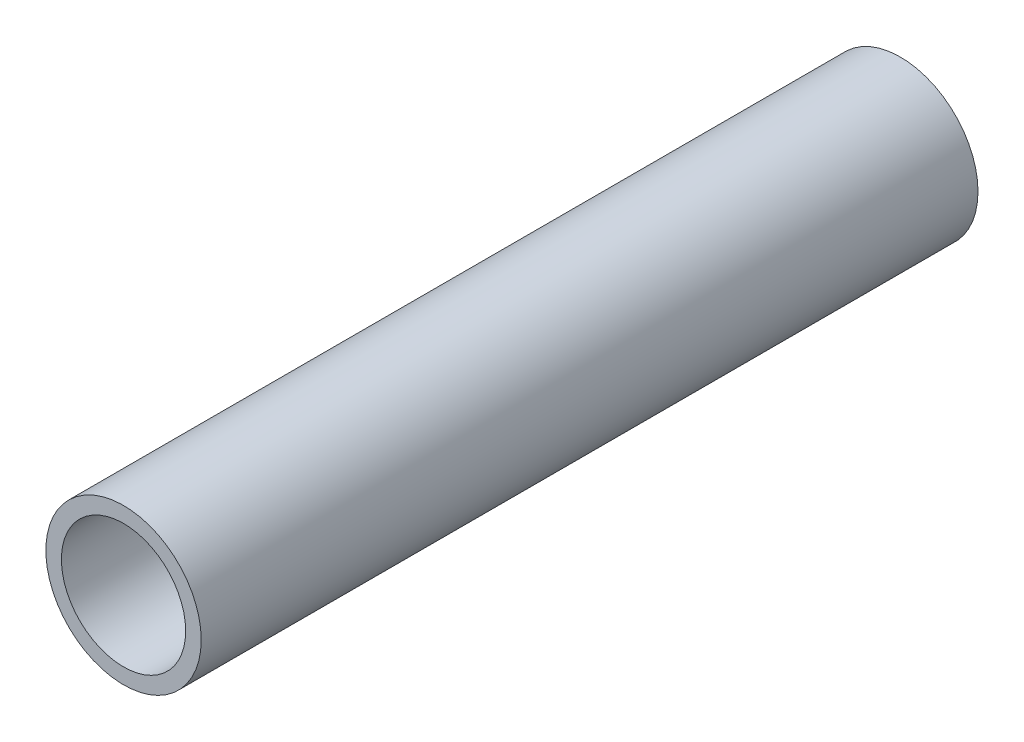
from build123d import *

# Parameters (mm, degrees)
SKETCH1_R           = 12.7
SKETCH1_R_2         = 10.16
EXTRUDE_THIN1_DEPTH = 127


with BuildPart() as part:
    # Sketch1 → Extrude-Thin1 (new body)
    with BuildSketch(Plane.XY):
        Circle(SKETCH1_R)
        Circle(SKETCH1_R_2, mode=Mode.SUBTRACT)
    extrude(amount=EXTRUDE_THIN1_DEPTH)


solid = part.part
